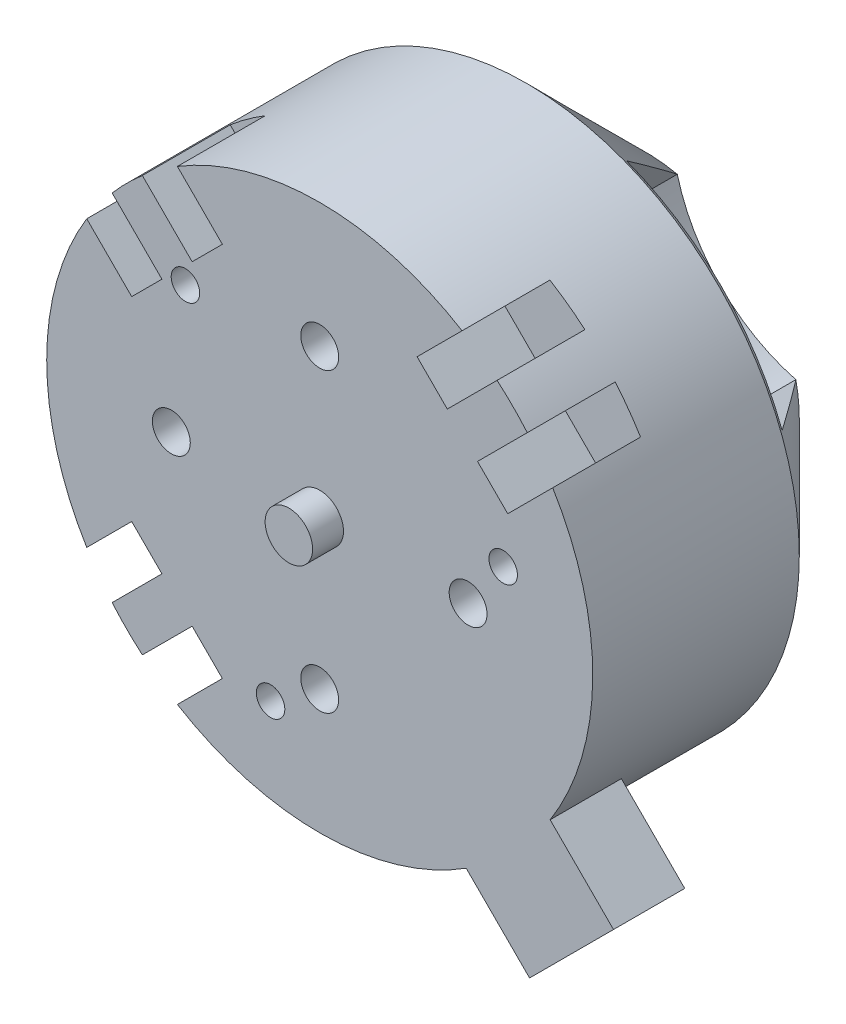
from build123d import *

# Parameters (mm, degrees)
SKETCH_1_R          = 23
EXTRUDE_1_DEPTH     = 25
SKETCH_2_R          = 1.5
SKETCH_2_R_2        = 2.6
CUT_EXTRUDE_1_DEPTH = 10
SKETCH_3_R          = 2.6
EXTRUDE_2_DEPTH     = 27
CHAMFER_1_SIZE      = 10
CUT_EXTRUDE_2_DEPTH = 9.5
SKETCH_5_R          = 1.595744681
CUT_EXTRUDE_3_DEPTH = 2
SKETCH_6_R          = 2.6
CUT_EXTRUDE_4_DEPTH = 12
SKETCH_7_R          = 2
EXTRUDE_3_DEPTH     = 5
EXTRUDE_4_DEPTH     = 5
CUT_EXTRUDE_5_DEPTH = 5
SKETCH_10_R         = 1.595744681
EXTRUDE_5_DEPTH     = 2.4
CUT_EXTRUDE_6_DEPTH = 1.4
SKETCH_12_R         = 1.2
CUT_EXTRUDE_7_DEPTH = 5


with BuildPart() as part:
    # 草图1 → 凸台-拉伸1 (new body)
    with BuildSketch(Plane.XY):
        Circle(SKETCH_1_R)
    extrude(amount=EXTRUDE_1_DEPTH)

    # 草图2 → 切除-拉伸1 (cut)
    with BuildSketch(Plane(origin=(0, 0, 0), x_dir=(-1, 0, 0), z_dir=(0, 0, -1))):
        with Locations((6, 0)):
            Circle(SKETCH_2_R)
        with Locations((0, -6)):
            Circle(SKETCH_2_R)
        with Locations((-6, 0)):
            Circle(SKETCH_2_R)
        with Locations((0, 6)):
            Circle(SKETCH_2_R)
        Circle(SKETCH_2_R_2)
    extrude(amount=-CUT_EXTRUDE_1_DEPTH, mode=Mode.SUBTRACT)

    # 草图3 → 凸台-拉伸2 (add)
    with BuildSketch(Plane(origin=(0, 0, 10), x_dir=(-1, 0, 0), z_dir=(0, 0, -1))):
        Circle(SKETCH_3_R)
    extrude(amount=-EXTRUDE_2_DEPTH)

    # 倒角1
    chamfer_1_edges = [part.edges().sort_by_distance(p)[0] for p in [
        (-23, 0, 0),
    ]]
    chamfer(chamfer_1_edges, length=CHAMFER_1_SIZE)

    # 草图4 → 切除-拉伸2 (cut)
    with BuildSketch(Plane(origin=(0, 0, 0), x_dir=(-1, 0, 0), z_dir=(0, 0, -1))):
        with BuildLine():
            ThreePointArc((3.800832161, -12.431961828), (3.264127324, -12.583539757), (2.72141518, -12.711958913))
            Line((2.72141518, -12.711958913), (8.204578209, -21.486854037))
            ThreePointArc((8.204578209, -21.486854037), (16.263455967, -16.263455967), (21.486854037, -8.204578209))
            Line((21.486854037, -8.204578209), (12.711958913, -2.72141518))
            ThreePointArc((12.711958913, -2.72141518), (9.578191182, -8.789667439), (3.800832161, -12.431961828))
        make_face()
        with BuildLine():
            ThreePointArc((12.711958913, -2.72141518), (6.363961031, -6.363961031), (2.72141518, -12.711958913))
            ThreePointArc((2.72141518, -12.711958913), (3.264127324, -12.583539757), (3.800832161, -12.431961828))
            ThreePointArc((3.800832161, -12.431961828), (9.578191182, -8.789667439), (12.711958913, -2.72141518))
        make_face()
        with BuildLine():
            ThreePointArc((2.72141518, 12.711958913), (6.363961031, 6.363961031), (12.711958913, 2.72141518))
            ThreePointArc((12.711958913, 2.72141518), (9.192388155, 9.192388155), (2.72141518, 12.711958913))
        make_face()
        with BuildLine():
            ThreePointArc((2.72141518, 12.711958913), (9.192388155, 9.192388155), (12.711958913, 2.72141518))
            Line((12.711958913, 2.72141518), (21.486854037, 8.204578209))
            ThreePointArc((21.486854037, 8.204578209), (16.263455967, 16.263455967), (8.204578209, 21.486854037))
            Line((8.204578209, 21.486854037), (2.72141518, 12.711958913))
        make_face()
        with BuildLine():
            Line((-21.486854037, 8.204578209), (-12.711958913, 2.72141518))
            ThreePointArc((-12.711958913, 2.72141518), (-9.192388155, 9.192388155), (-2.72141518, 12.711958913))
            Line((-2.72141518, 12.711958913), (-8.204578209, 21.486854037))
            ThreePointArc((-8.204578209, 21.486854037), (-16.263455967, 16.263455967), (-21.486854037, 8.204578209))
        make_face()
        with BuildLine():
            ThreePointArc((-2.72141518, 12.711958913), (-9.192388155, 9.192388155), (-12.711958913, 2.72141518))
            ThreePointArc((-12.711958913, 2.72141518), (-6.363961031, 6.363961031), (-2.72141518, 12.711958913))
        make_face()
        with BuildLine():
            Line((-8.204578209, -21.486854037), (-2.72141518, -12.711958913))
            ThreePointArc((-2.72141518, -12.711958913), (-9.192388155, -9.192388155), (-12.711958913, -2.72141518))
            Line((-12.711958913, -2.72141518), (-21.486854037, -8.204578209))
            ThreePointArc((-21.486854037, -8.204578209), (-16.263455967, -16.263455967), (-8.204578209, -21.486854037))
        make_face()
        with BuildLine():
            ThreePointArc((-12.711958913, -2.72141518), (-9.192388155, -9.192388155), (-2.72141518, -12.711958913))
            ThreePointArc((-2.72141518, -12.711958913), (-6.363961031, -6.363961031), (-12.711958913, -2.72141518))
        make_face()
    extrude(amount=-CUT_EXTRUDE_2_DEPTH, mode=Mode.SUBTRACT)

    # 草图5 → 切除-拉伸3 (cut)
    with BuildSketch(Plane.XY.offset(25)):
        with Locations((0, 12.5)):
            Circle(SKETCH_5_R)
        with Locations((12.5, 0)):
            Circle(SKETCH_5_R)
        with Locations((0, -12.5)):
            Circle(SKETCH_5_R)
        with Locations((-12.5, 0)):
            Circle(SKETCH_5_R)
    extrude(amount=-CUT_EXTRUDE_3_DEPTH, mode=Mode.SUBTRACT)

    # 草图6 → 切除-拉伸4 (cut)
    with BuildSketch(Plane.XY.offset(37)):
        Circle(SKETCH_6_R)
    extrude(amount=-CUT_EXTRUDE_4_DEPTH, mode=Mode.SUBTRACT)

    # 草图7 → 凸台-拉伸3 (add)
    with BuildSketch(Plane.XY.offset(25)):
        Circle(SKETCH_7_R)
    extrude(amount=EXTRUDE_3_DEPTH)

    # 草图8 → 凸台-拉伸4 (add)
    with BuildSketch(Plane.XY.offset(25)):
        Polygon((17.67766953, -24.748737342), (24.748737342, -17.67766953), (17.597575781, -10.526507969), (10.526507969, -17.597575781), align=None)
    extrude(amount=-EXTRUDE_4_DEPTH)

    # 草图9 → 切除-拉伸5 (cut)
    with BuildSketch(Plane.XY.offset(25)):
        with BuildLine():
            Line((-17.335793171, 14.790208759), (-17.486366766, 14.940782353))
            ThreePointArc((-17.486366766, 14.940782353), (-18.615341136, 13.50811143), (-19.627234895, 11.990481658))
            Line((-19.627234895, 11.990481658), (-15.839191899, 8.202438662))
            Line((-15.839191899, 8.202438662), (-13.293607486, 10.748023074))
            Line((-13.293607486, 10.748023074), (-17.335793171, 14.790208759))
        make_face()
        with BuildLine():
            Line((-8.202438662, 15.839191899), (-11.990481658, 19.627234895))
            ThreePointArc((-11.990481658, 19.627234895), (-13.50811143, 18.615341136), (-14.940782353, 17.486366766))
            Line((-14.940782353, 17.486366766), (-14.790208759, 17.335793171))
            Line((-14.790208759, 17.335793171), (-10.748023074, 13.293607486))
            Line((-10.748023074, 13.293607486), (-8.202438662, 15.839191899))
        make_face()
        with BuildLine():
            Line((8.202438662, 15.839191899), (10.748023074, 13.293607486))
            Line((10.748023074, 13.293607486), (14.790208759, 17.335793171))
            Line((14.790208759, 17.335793171), (14.940782353, 17.486366766))
            ThreePointArc((14.940782353, 17.486366766), (13.50811143, 18.615341136), (11.990481658, 19.627234895))
            Line((11.990481658, 19.627234895), (8.202438662, 15.839191899))
        make_face()
        with BuildLine():
            ThreePointArc((19.627234895, 11.990481658), (18.615341136, 13.50811143), (17.486366766, 14.940782353))
            Line((17.486366766, 14.940782353), (17.335793171, 14.790208759))
            Line((17.335793171, 14.790208759), (13.293607486, 10.748023074))
            Line((13.293607486, 10.748023074), (15.839191899, 8.202438662))
            Line((15.839191899, 8.202438662), (19.627234895, 11.990481658))
        make_face()
        with BuildLine():
            Line((-14.790208759, -17.335793171), (-14.940782353, -17.486366766))
            ThreePointArc((-14.940782353, -17.486366766), (-13.50811143, -18.615341136), (-11.990481658, -19.627234895))
            Line((-11.990481658, -19.627234895), (-8.202438662, -15.839191899))
            Line((-8.202438662, -15.839191899), (-10.748023074, -13.293607486))
            Line((-10.748023074, -13.293607486), (-14.790208759, -17.335793171))
        make_face()
        with BuildLine():
            Line((-15.839191899, -8.202438662), (-19.627234895, -11.990481658))
            ThreePointArc((-19.627234895, -11.990481658), (-18.615341136, -13.50811143), (-17.486366766, -14.940782353))
            Line((-17.486366766, -14.940782353), (-17.335793171, -14.790208759))
            Line((-17.335793171, -14.790208759), (-13.293607486, -10.748023074))
            Line((-13.293607486, -10.748023074), (-15.839191899, -8.202438662))
        make_face()
    extrude(amount=-CUT_EXTRUDE_5_DEPTH, mode=Mode.SUBTRACT)

    # 草图10 → 凸台-拉伸5 (add)
    with BuildSketch(Plane.XY.offset(25)):
        with BuildLine():
            Line((-10.748023074, -13.293607486), (-8.202438662, -15.839191899))
            Line((-8.202438662, -15.839191899), (-11.990481658, -19.627234895))
            ThreePointArc((-11.990481658, -19.627234895), (0.205316668, -22.99908357), (12.33897396, -19.410041772))
            Line((12.33897396, -19.410041772), (17.67766953, -24.748737342))
            Line((17.67766953, -24.748737342), (24.748737342, -17.67766953))
            Line((24.748737342, -17.67766953), (19.410041772, -12.33897396))
            ThreePointArc((19.410041772, -12.33897396), (22.99908357, -0.205316668), (19.627234895, 11.990481658))
            Line((19.627234895, 11.990481658), (15.839191899, 8.202438662))
            Line((15.839191899, 8.202438662), (13.293607486, 10.748023074))
            Line((13.293607486, 10.748023074), (17.486366766, 14.940782353))
            ThreePointArc((17.486366766, 14.940782353), (16.263455967, 16.263455967), (14.940782353, 17.486366766))
            Line((14.940782353, 17.486366766), (10.748023074, 13.293607486))
            Line((10.748023074, 13.293607486), (8.202438662, 15.839191899))
            Line((8.202438662, 15.839191899), (11.990481658, 19.627234895))
            ThreePointArc((11.990481658, 19.627234895), (0, 23), (-11.990481658, 19.627234895))
            Line((-11.990481658, 19.627234895), (-8.202438662, 15.839191899))
            Line((-8.202438662, 15.839191899), (-10.748023074, 13.293607486))
            Line((-10.748023074, 13.293607486), (-14.940782353, 17.486366766))
            ThreePointArc((-14.940782353, 17.486366766), (-16.263455967, 16.263455967), (-17.486366766, 14.940782353))
            Line((-17.486366766, 14.940782353), (-13.293607486, 10.748023074))
            Line((-13.293607486, 10.748023074), (-15.839191899, 8.202438662))
            Line((-15.839191899, 8.202438662), (-19.627234895, 11.990481658))
            ThreePointArc((-19.627234895, 11.990481658), (-23, 0), (-19.627234895, -11.990481658))
            Line((-19.627234895, -11.990481658), (-15.839191899, -8.202438662))
            Line((-15.839191899, -8.202438662), (-13.293607486, -10.748023074))
            Line((-13.293607486, -10.748023074), (-17.486366766, -14.940782353))
            ThreePointArc((-17.486366766, -14.940782353), (-16.263455967, -16.263455967), (-14.940782353, -17.486366766))
            Line((-14.940782353, -17.486366766), (-10.748023074, -13.293607486))
        make_face()
        with Locations((0, 12.5)):
            Circle(SKETCH_10_R, mode=Mode.SUBTRACT)
        with Locations((-12.5, 0)):
            Circle(SKETCH_10_R, mode=Mode.SUBTRACT)
        with Locations((0, -12.5)):
            Circle(SKETCH_10_R, mode=Mode.SUBTRACT)
        with Locations((12.5, 0)):
            Circle(SKETCH_10_R, mode=Mode.SUBTRACT)
    extrude(amount=EXTRUDE_5_DEPTH)

    # 草图11 → 切除-拉伸6 (cut)
    with BuildSketch(Plane(origin=(0, 0, 20), x_dir=(-1, 0, 0), z_dir=(0, 0, -1))):
        with BuildLine():
            Line((-17.67766953, -24.748737342), (-12.33897396, -19.410041772))
            ThreePointArc((-12.33897396, -19.410041772), (-16.263455967, -16.263455967), (-19.410041772, -12.33897396))
            Line((-19.410041772, -12.33897396), (-24.748737342, -17.67766953))
            Line((-24.748737342, -17.67766953), (-17.67766953, -24.748737342))
        make_face()
    extrude(amount=-CUT_EXTRUDE_6_DEPTH, mode=Mode.SUBTRACT)

    # 草图12 → 切除-拉伸7 (cut)
    with BuildSketch(Plane.XY.offset(27.4)):
        with Locations((15.454813221, 4.141104722)):
            Circle(SKETCH_12_R)
        with Locations((-4.141104722, -15.454813221)):
            Circle(SKETCH_12_R)
        with Locations((-11.313708499, 11.313708499)):
            Circle(SKETCH_12_R)
    extrude(amount=-CUT_EXTRUDE_7_DEPTH, mode=Mode.SUBTRACT)


solid = part.part
